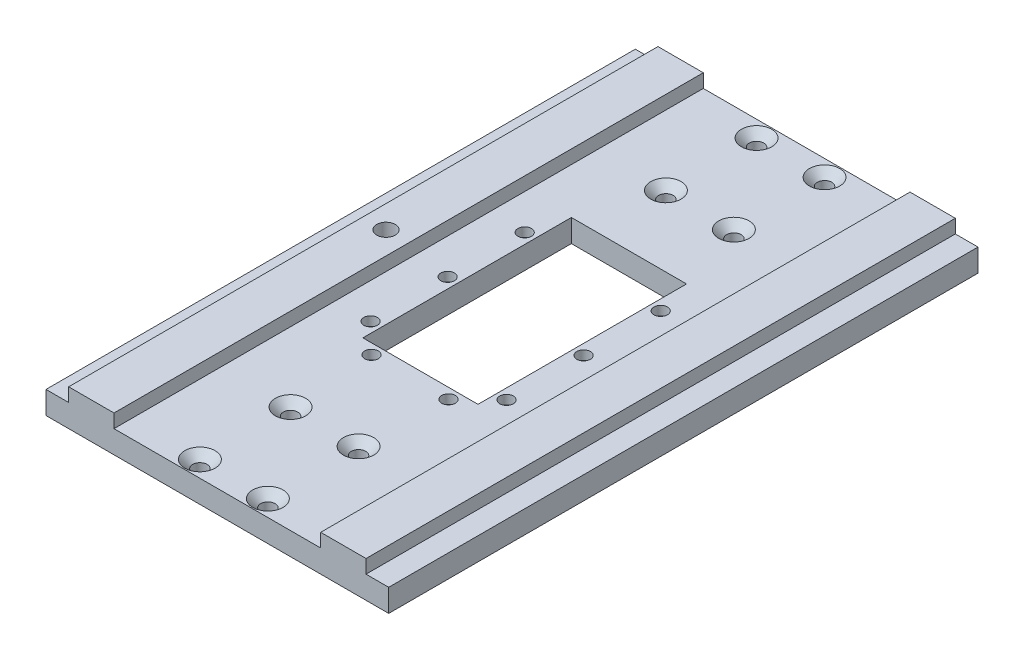
from build123d import *

# Parameters (mm, degrees)
SKETCH2_R           = 1.6
SKETCH2_R_2         = 1.5
SKETCH2_W           = 25.4
SKETCH2_H           = 46
BOSS_EXTRUDE1_DEPTH = 2
SKETCH5_R           = 1.6
SKETCH5_R_2         = 2.25
SKETCH5_W           = 25.4
SKETCH5_H           = 46
BOSS_EXTRUDE3_DEPTH = 3
SKETCH2_4_W         = 10
SKETCH2_4_H         = 30
SKETCH2_4_H_2       = 70
BOSS_EXTRUDE4_DEPTH = 5
CHAMFER1_SIZE       = 1.75
SKETCH7_R           = 2.05
CUT_EXTRUDE1_DEPTH  = 9


with BuildPart() as part:
    # Sketch2 → Boss-Extrude1 (new body)
    with BuildSketch(Plane(origin=(0, 0, 0), x_dir=(1, 0, 0), z_dir=(0, 1, 0))):
        Polygon((9.15, 64.2), (-37.8, 64.2), (-37.8, -65.8), (9.15, -65.8), (37.8, -65.8), (37.8, 64.2), align=None)
        with Locations((-7.45, -62.2)):
            Circle(SKETCH2_R, mode=Mode.SUBTRACT)
        with Locations((-7.45, -42.2)):
            Circle(SKETCH2_R, mode=Mode.SUBTRACT)
        with Locations((-15, -17)):
            Circle(SKETCH2_R_2, mode=Mode.SUBTRACT)
        with Locations((-8.5, -23.3)):
            Circle(SKETCH2_R_2, mode=Mode.SUBTRACT)
        with BuildLine():
            ThreePointArc((5.95, -62.2), (7.55, -60.6), (9.15, -62.2))
            ThreePointArc((9.15, -62.2), (7.55, -63.8), (5.95, -62.2))
        make_face(mode=Mode.SUBTRACT)
        with BuildLine():
            ThreePointArc((5.95, -42.2), (7.55, -40.6), (9.15, -42.2))
            ThreePointArc((9.15, -42.2), (7.55, -43.8), (5.95, -42.2))
        make_face(mode=Mode.SUBTRACT)
        with Locations((8.5, -23.3)):
            Circle(SKETCH2_R_2, mode=Mode.SUBTRACT)
        with Locations((15, -17)):
            Circle(SKETCH2_R_2, mode=Mode.SUBTRACT)
        with Locations((-15, 0)):
            Circle(SKETCH2_R_2, mode=Mode.SUBTRACT)
        with Locations((-15, 17)):
            Circle(SKETCH2_R_2, mode=Mode.SUBTRACT)
        with Locations((-7.45, 40.6)):
            Circle(SKETCH2_R, mode=Mode.SUBTRACT)
        with Locations((-7.45, 60.6)):
            Circle(SKETCH2_R, mode=Mode.SUBTRACT)
        with Locations((0, 2)):
            Rectangle(SKETCH2_W, SKETCH2_H, mode=Mode.SUBTRACT)
        with Locations((15, 0)):
            Circle(SKETCH2_R_2, mode=Mode.SUBTRACT)
        with Locations((15, 17)):
            Circle(SKETCH2_R_2, mode=Mode.SUBTRACT)
        with BuildLine():
            ThreePointArc((7.55, 39), (6.41862915, 39.46862915), (5.95, 40.6))
            ThreePointArc((5.95, 40.6), (8.68137085, 41.73137085), (7.55, 39))
        make_face(mode=Mode.SUBTRACT)
        with Locations((7.55, 60.6)):
            Circle(SKETCH2_R, mode=Mode.SUBTRACT)
    extrude(amount=BOSS_EXTRUDE1_DEPTH)

    # Sketch5 → Boss-Extrude3 (add)
    with BuildSketch(Plane.XZ):
        Polygon((37.8, 30.8), (37.8, 65.8), (-37.8, 65.8), (-37.8, 30.8), (-37.8, -29.2), (-37.8, -64.2), (37.8, -64.2), (37.8, -29.2), align=None)
        with Locations((-7.45, -60.6)):
            Circle(SKETCH5_R, mode=Mode.SUBTRACT)
        with Locations((-7.45, -40.6)):
            Circle(SKETCH5_R, mode=Mode.SUBTRACT)
        with Locations((-15, -17)):
            Circle(SKETCH5_R_2, mode=Mode.SUBTRACT)
        with Locations((-15, 0)):
            Circle(SKETCH5_R_2, mode=Mode.SUBTRACT)
        with Locations((0, -2)):
            Rectangle(SKETCH5_W, SKETCH5_H, mode=Mode.SUBTRACT)
        with Locations((7.55, -60.6)):
            Circle(SKETCH5_R, mode=Mode.SUBTRACT)
        with Locations((7.55, -40.6)):
            Circle(SKETCH5_R, mode=Mode.SUBTRACT)
        with Locations((15, -17)):
            Circle(SKETCH5_R_2, mode=Mode.SUBTRACT)
        with Locations((15, 0)):
            Circle(SKETCH5_R_2, mode=Mode.SUBTRACT)
        with Locations((-15, 17)):
            Circle(SKETCH5_R_2, mode=Mode.SUBTRACT)
        with Locations((-8.5, 23.3)):
            Circle(SKETCH5_R_2, mode=Mode.SUBTRACT)
        with Locations((-7.45, 42.2)):
            Circle(SKETCH5_R, mode=Mode.SUBTRACT)
        with Locations((-7.45, 62.2)):
            Circle(SKETCH5_R, mode=Mode.SUBTRACT)
        with Locations((15, 17)):
            Circle(SKETCH5_R_2, mode=Mode.SUBTRACT)
        with Locations((8.5, 23.3)):
            Circle(SKETCH5_R_2, mode=Mode.SUBTRACT)
        with Locations((7.55, 42.2)):
            Circle(SKETCH5_R, mode=Mode.SUBTRACT)
        with Locations((7.55, 62.2)):
            Circle(SKETCH5_R, mode=Mode.SUBTRACT)
    extrude(amount=BOSS_EXTRUDE3_DEPTH)

    # Sketch2_4 → Boss-Extrude4 (add)
    with BuildSketch(Plane(origin=(0, 0, 0), x_dir=(1, 0, 0), z_dir=(0, 1, 0))):
        with Locations((27.8, 49.2)):
            Rectangle(SKETCH2_4_W, SKETCH2_4_H)
        with Locations((27.8, -0.8)):
            Rectangle(SKETCH2_4_W, SKETCH2_4_H_2)
        with Locations((27.8, -50.8)):
            Rectangle(SKETCH2_4_W, SKETCH2_4_H)
        with Locations((-27.8, 49.2)):
            Rectangle(SKETCH2_4_W, SKETCH2_4_H)
        with Locations((-27.8, -0.8)):
            Rectangle(SKETCH2_4_W, SKETCH2_4_H_2)
        with Locations((-27.8, -50.8)):
            Rectangle(SKETCH2_4_W, SKETCH2_4_H)
    extrude(amount=BOSS_EXTRUDE4_DEPTH)

    # Chamfer1
    chamfer1_edges = [part.edges().sort_by_distance(p)[0] for p in [
        (-9.05, 2, 42.2),
        (9.15, 2, 42.2),
        (9.15, 2, 62.2),
        (-9.05, 2, 62.2),
        (-9.05, 2, -40.6),
        (-9.05, 2, -60.6),
        (5.95, 2, -60.6),
        (7.55, 2, -42.2),
    ]]
    chamfer(chamfer1_edges, length=CHAMFER1_SIZE)

    # Sketch7 → Cut-Extrude1 (cut, through all)
    with BuildSketch(Plane(origin=(0, 5, 0), x_dir=(1, 0, 0), z_dir=(0, 1, 0))):
        with Locations((-27.8, -0.8)):
            Circle(SKETCH7_R)
    extrude(amount=-CUT_EXTRUDE1_DEPTH, mode=Mode.SUBTRACT)


solid = part.part
